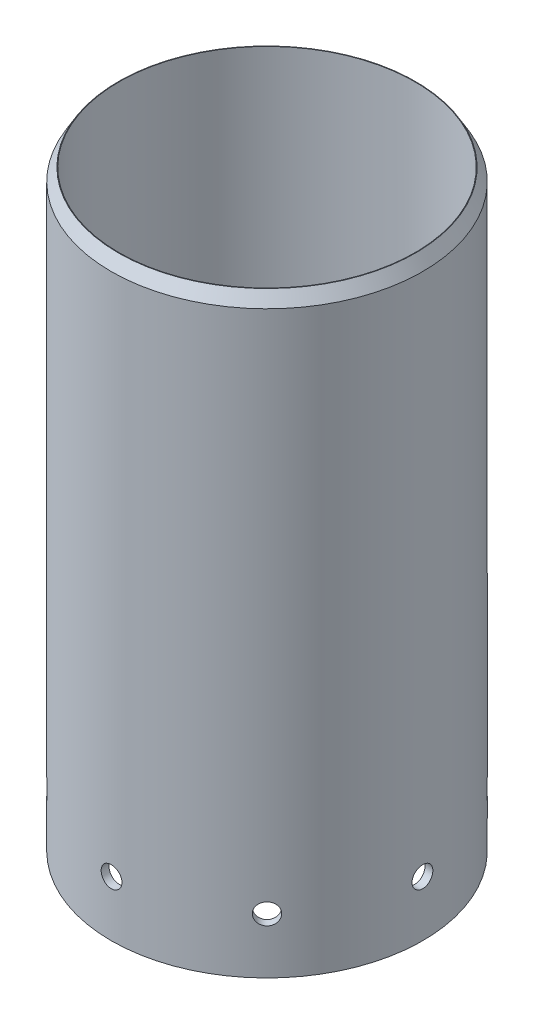
from build123d import *

# Parameters (mm, degrees)
SKETCH1_R           = 106.934
SKETCH1_R_2         = 101.6
BOSS_EXTRUDE1_DEPTH = 406.4
CHAMFER2_SIZE       = 8.551418
CHAMFER2_SIZE2      = 4.937125
CUT_EXTRUDE1_START  = -5.585459
SKETCH6_R           = 7.14375
CUT_EXTRUDE1_DEPTH  = 5.585459
CIRPATTERN1_COUNT   = 8


with BuildPart() as part:
    # Sketch1 → Boss-Extrude1 (new body)
    with BuildSketch(Plane(origin=(0, 0, 0), x_dir=(1, 0, 0), z_dir=(0, 1, 0))):
        Circle(SKETCH1_R)
        Circle(SKETCH1_R_2, mode=Mode.SUBTRACT)
    extrude(amount=BOSS_EXTRUDE1_DEPTH)

    # Chamfer2
    chamfer2_edges = [part.edges().sort_by_distance(p)[0] for p in [
        (-106.934, 406.4, 0),
    ]]
    chamfer2_side = [part.faces().sort_by_distance(p)[0] for p in [
        (-106.934, 203.2, 0),
    ]]
    chamfer(chamfer2_edges, length=CHAMFER2_SIZE, length2=CHAMFER2_SIZE2, reference=chamfer2_side[0])

    # Sketch6 → Cut-Extrude1 (cut)
    with BuildSketch(Plane(origin=(106.934, 0, 0), x_dir=(0, 0, -1), z_dir=(1, 0, 0)).offset(CUT_EXTRUDE1_START)):
        with Locations((0, 38.1)):
            Circle(SKETCH6_R)
    cut_extrude1 = extrude(amount=CUT_EXTRUDE1_DEPTH, mode=Mode.SUBTRACT)

    # CirPattern1: Cut-Extrude1 ×8 about axis
    cirpattern1_axis = Axis((0, 406.4, 0), (0, -1, 0))
    for i in range(1, CIRPATTERN1_COUNT):
        add(cut_extrude1.rotate(cirpattern1_axis, i * 360 / CIRPATTERN1_COUNT), mode=Mode.SUBTRACT)


solid = part.part
